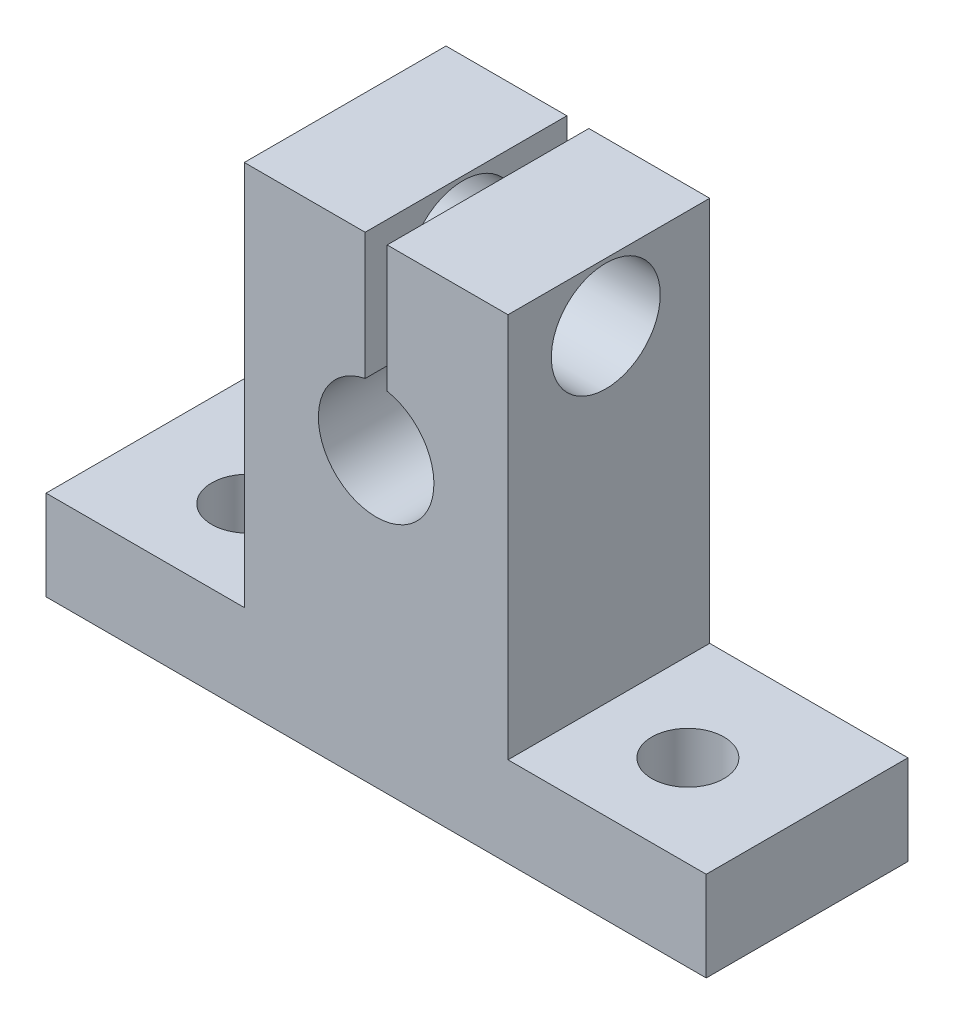
from build123d import *

# Parameters (mm, degrees)
SKETCH1_W              = 18.2626
SKETCH1_H              = 32.9184
MAIN_BODY_DEPTH        = 13.97
SKETCH2_W              = 45.72
SKETCH2_H              = 6.223
BOTTOM_BODY_DEPTH      = 13.97
SKETCH3_R              = 4.0005
CENTER_HOLE_DEPTH      = 1
CENTER_HOLE_DEPTH_BACK = 14.97
SKETCH4_W              = 1.524
SKETCH4_H              = 24.062462206
CENTER_CUT_DEPTH       = 14.97
SKETCH5_R              = 3.7719
SIDE_HOLE_DEPTH        = 32.9913
F_5_0MM_DOWEL_HOLE1_D  = 5


with BuildPart() as part:
    # Sketch1 → Main Body] (new body)
    with BuildSketch(Plane.XY):
        Rectangle(SKETCH1_W, SKETCH1_H)
    extrude(amount=MAIN_BODY_DEPTH)

    # Sketch2 → Bottom Body (add)
    with BuildSketch(Plane.XY.offset(13.97)):
        with Locations((0, -13.3477)):
            Rectangle(SKETCH2_W, SKETCH2_H)
    extrude(amount=-BOTTOM_BODY_DEPTH)

    # Sketch3 → Center Hole (cut, two sides)
    with BuildSketch(Plane.XY.offset(13.97)) as center_hole_sk:
        with Locations((0, 3.7592)):
            Circle(SKETCH3_R)
    extrude(amount=CENTER_HOLE_DEPTH, mode=Mode.SUBTRACT)
    extrude(center_hole_sk.sketch, amount=-CENTER_HOLE_DEPTH_BACK, mode=Mode.SUBTRACT)

    # Sketch4 → Center Cut (cut, through all)
    with BuildSketch(Plane.XY.offset(13.97)):
        with Locations((0, 16.4592)):
            Rectangle(SKETCH4_W, SKETCH4_H)
    extrude(amount=-CENTER_CUT_DEPTH, mode=Mode.SUBTRACT)

    # Sketch5 → Side Hole (cut, through all)
    with BuildSketch(Plane(origin=(9.1313, 0, 0), x_dir=(0, 0, -1), z_dir=(1, 0, 0))):
        with Locations((-7.196820587, 12.3952)):
            Circle(SKETCH5_R)
    extrude(amount=-SIDE_HOLE_DEPTH, mode=Mode.SUBTRACT)

    # Ø5.0mm Dowel Hole1 (through all)
    with Locations(Plane(origin=(0, -10.2362, 0), x_dir=(1, 0, 0), z_dir=(0, 1, 0))):
        with Locations((15.24, -7.62)):
            f_5_0mm_dowel_hole1 = Hole(F_5_0MM_DOWEL_HOLE1_D / 2)

    # Mirror1: Ø5.0mm Dowel Hole1 across plane
    add(f_5_0mm_dowel_hole1.mirror(Plane(origin=(0, 0, 0), x_dir=(0, 0, 1), z_dir=(1, 0, 0))), mode=Mode.SUBTRACT)


solid = part.part
